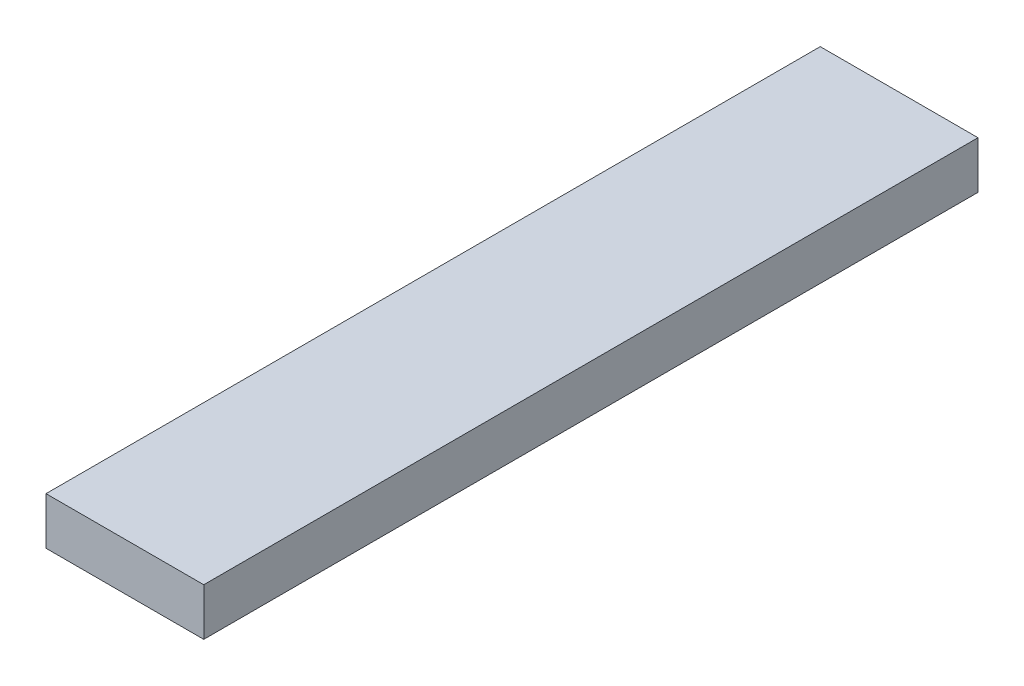
from build123d import *

# Parameters (mm, degrees)
SKETCH1_W           = 10
SKETCH1_H           = 49.08
BOSS_EXTRUDE1_DEPTH = 3


with BuildPart() as part:
    # Sketch1 → Boss-Extrude1 (new body)
    with BuildSketch(Plane(origin=(0, 0, 0), x_dir=(1, 0, 0), z_dir=(0, 1, 0))):
        with Locations((5, 24.54)):
            Rectangle(SKETCH1_W, SKETCH1_H)
    extrude(amount=BOSS_EXTRUDE1_DEPTH)


solid = part.part
